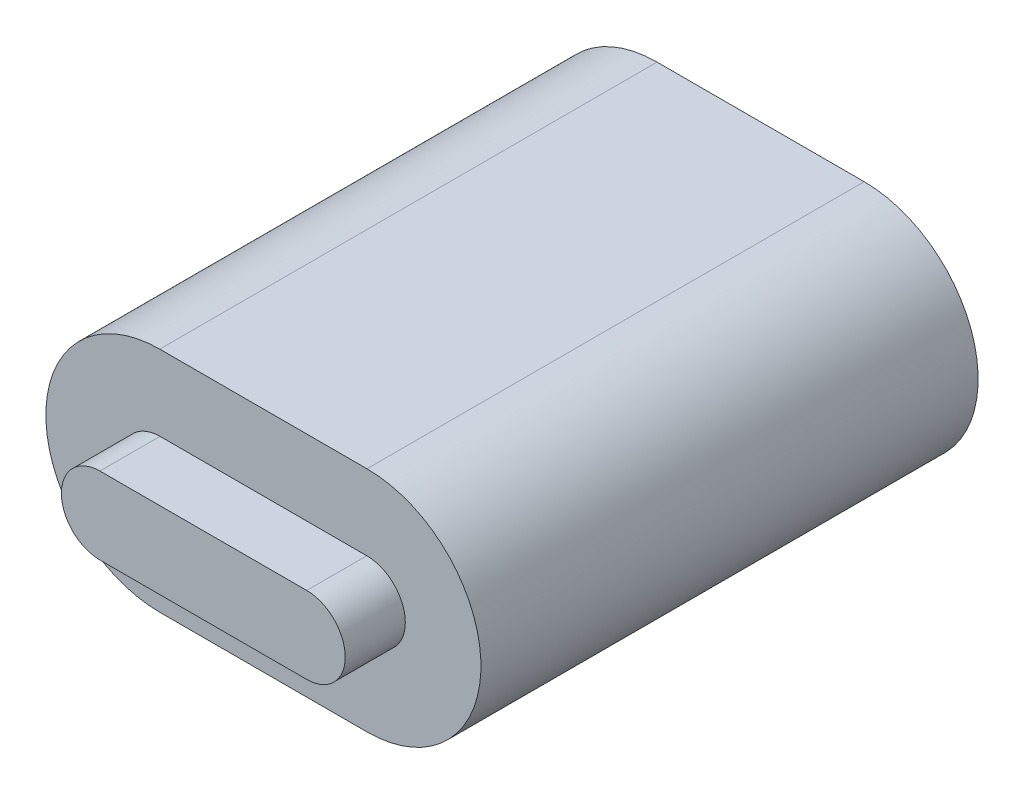
from build123d import *

# Parameters (mm, degrees)
BOSS_EXTRUDE1_DEPTH = 1.45
BOSS_EXTRUDE2_DEPTH = 12


with BuildPart() as part:
    # Sketch1 → Boss-Extrude1 (new body)
    with BuildSketch(Plane.XY):
        with BuildLine():
            Line((-2.495, 0.93), (2.495, 0.93))
            ThreePointArc((2.495, 0.93), (3.425, 0), (2.495, -0.93))
            Line((2.495, -0.93), (-2.495, -0.93))
            ThreePointArc((-2.495, -0.93), (-3.425, 0), (-2.495, 0.93))
        make_face()
    extrude(amount=BOSS_EXTRUDE1_DEPTH)

    # Sketch2 → Boss-Extrude2 (add)
    with BuildSketch(Plane(origin=(0, 0, 0), x_dir=(-1, 0, 0), z_dir=(0, 0, -1))):
        with BuildLine():
            Line((-2.5, 2.75), (2.5, 2.75))
            ThreePointArc((2.5, 2.75), (5.25, 0), (2.5, -2.75))
            Line((2.5, -2.75), (-2.5, -2.75))
            ThreePointArc((-2.5, -2.75), (-5.25, 0), (-2.5, 2.75))
        make_face()
    extrude(amount=BOSS_EXTRUDE2_DEPTH)


solid = part.part
